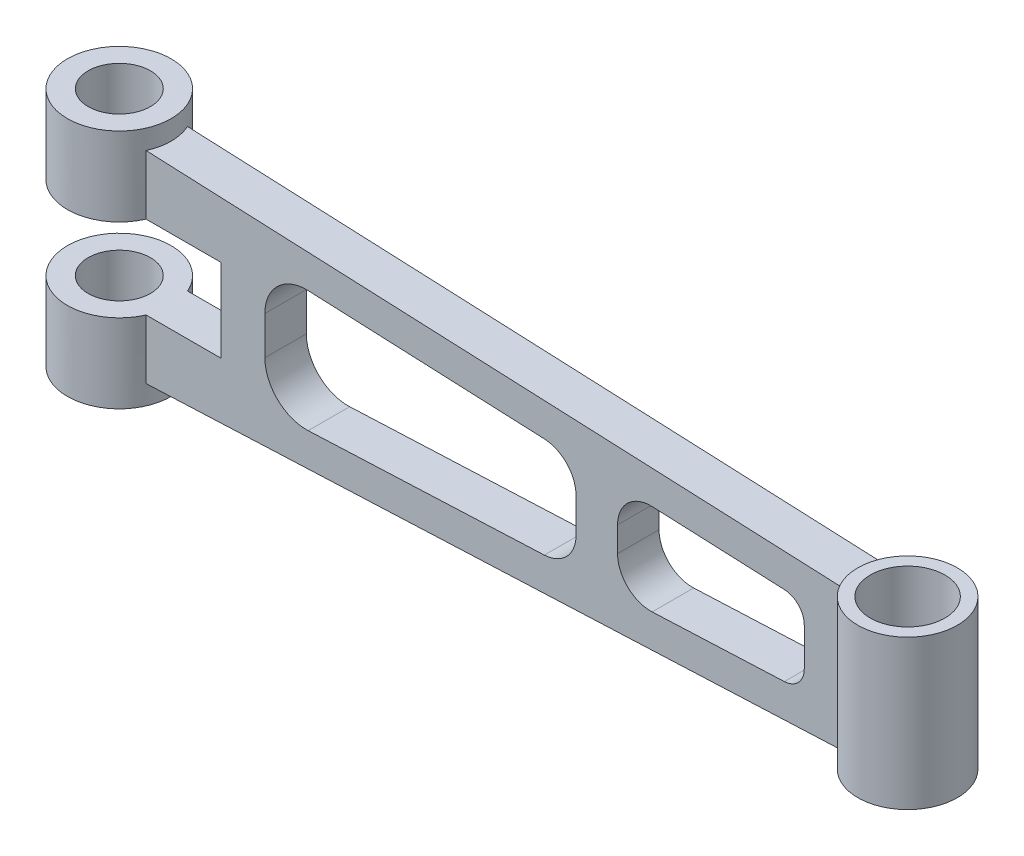
from build123d import *

# Parameters (mm, degrees)
SKETCH1_R               = 12.5
SKETCH1_R_2             = 7.5
SKETCH1_R_3             = 12
SKETCH1_R_4             = 9
SKETCH1_W               = 167.634848648
SKETCH1_H               = 10
BOSS_EXTRUDE1_DEPTH     = 58
SKETCH2_W               = 22.908712115
SKETCH2_H               = 11
SKETCH2_W_2             = 18.043560763
SKETCH2_H_2             = 20
SKETCH2_W_3             = 23.956439237
CUT_EXTRUDE1_DEPTH      = 8.5
CUT_EXTRUDE1_DEPTH_BACK = 18.5
BOSS_EXTRUDE2_START     = -0.99133
BOSS_EXTRUDE2_DEPTH     = 0.99133
BOSS_EXTRUDE3_START     = -4.717797
BOSS_EXTRUDE3_DEPTH     = 4.717797
FILLET1_R               = 5
FILLET2_R               = 8
FILLET3_R               = 10


with BuildPart() as part:
    # Sketch1 → Boss-Extrude1 (new body)
    with BuildSketch(Plane(origin=(0, 0, 0), x_dir=(1, 0, 0), z_dir=(0, 1, 0))):
        Circle(SKETCH1_R)
        Circle(SKETCH1_R_2, mode=Mode.SUBTRACT)
        with Locations((190, 0)):
            Circle(SKETCH1_R_3)
        with Locations((190, 0)):
            Circle(SKETCH1_R_4, mode=Mode.SUBTRACT)
        with Locations((95.273863561, 0)):
            Rectangle(SKETCH1_W, SKETCH1_H)
    extrude(amount=BOSS_EXTRUDE1_DEPTH)

    # Sketch2 → Cut-Extrude1 (cut, two sides)
    with BuildSketch(Plane(origin=(0, 0, -5), x_dir=(-1, 0, 0), z_dir=(0, 0, -1))) as cut_extrude1_sk:
        with Locations((-190.545643943, 52.5)):
            Rectangle(SKETCH2_W, SKETCH2_H)
        Polygon((-179.091287885, 47), (-179.091287885, 46.00867027), (-11.456439237, 53.327765826), (-11.456439237, 58), (-179.091287885, 58), align=None)
        with Locations((-190.545643943, 5.5)):
            Rectangle(SKETCH2_W, SKETCH2_H)
        Polygon((-179.091287885, 11.99132973), (-179.091287885, 11), (-179.091287885, 0), (-11.456439237, 0), (-11.456439237, 4.672234174), align=None)
        Polygon((-170.091287885, 19.606002726), (-170.091287885, 38.393997274), (-125.091287885, 40.358739705), (-125.091287885, 17.641260295), align=None)
        Polygon((-115.091287885, 17.204650866), (-115.091287885, 40.795349134), (-40.091287885, 44.069919853), (-40.091287885, 13.930080147), align=None)
        with Locations((-20.478219619, 29)):
            Rectangle(SKETCH2_W_2, SKETCH2_H_2)
        with Locations((0.521780381, 29)):
            Rectangle(SKETCH2_W_3, SKETCH2_H_2)
    extrude(amount=CUT_EXTRUDE1_DEPTH, mode=Mode.SUBTRACT)
    extrude(cut_extrude1_sk.sketch, amount=-CUT_EXTRUDE1_DEPTH_BACK, mode=Mode.SUBTRACT)

    # Sketch3 → Boss-Extrude2 (add)
    with BuildSketch(Plane.XZ.offset(-11).offset(BOSS_EXTRUDE2_START)):
        with BuildLine():
            Line((179.091287885, -5), (179.091287885, 5))
            ThreePointArc((179.091287885, 5), (178, 0), (179.091287885, -5))
        make_face()
    boss_extrude2 = extrude(amount=BOSS_EXTRUDE2_DEPTH)

    # Sketch4 → Boss-Extrude3 (add)
    with BuildSketch(Plane.XZ.offset(BOSS_EXTRUDE3_START)):
        with BuildLine():
            Line((11.456439237, 5), (11.456439237, -5))
            ThreePointArc((11.456439237, -5), (12.236328912, -2.553870546), (12.5, 0))
            ThreePointArc((12.5, 0), (12.236328912, 2.553870546), (11.456439237, 5))
        make_face()
    boss_extrude3 = extrude(amount=BOSS_EXTRUDE3_DEPTH)

    # Mirror1: Boss-Extrude2, Boss-Extrude3 across plane
    add(boss_extrude2.mirror(Plane(origin=(0, 29, 0), x_dir=(0, 0, 1), z_dir=(0, -1, 0))))
    add(boss_extrude3.mirror(Plane(origin=(0, 29, 0), x_dir=(0, 0, 1), z_dir=(0, -1, 0))))

    # Fillet1
    fillet1_edges = [part.edges().sort_by_distance(p)[0] for p in [
        (170.091287885, 19.606002726, 0),
        (170.091287885, 38.393997274, 0),
    ]]
    fillet(fillet1_edges, radius=FILLET1_R)

    # Fillet2
    fillet2_edges = [part.edges().sort_by_distance(p)[0] for p in [
        (115.091287885, 17.204650866, 0),
        (115.091287885, 40.795349134, 0),
        (125.091287885, 40.358739705, 0),
        (125.091287885, 17.641260295, 0),
    ]]
    fillet(fillet2_edges, radius=FILLET2_R)

    # Fillet3
    fillet3_edges = [part.edges().sort_by_distance(p)[0] for p in [
        (40.091287885, 44.069919853, 0),
        (40.091287885, 13.930080147, 0),
    ]]
    fillet(fillet3_edges, radius=FILLET3_R)


solid = part.part
